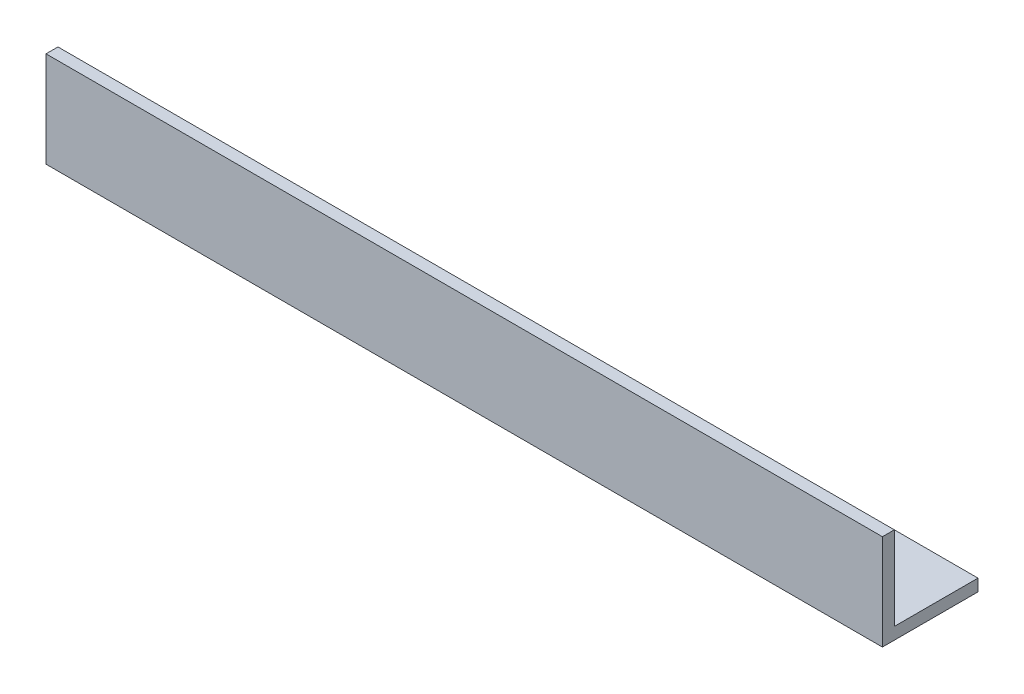
from build123d import *

# Parameters (mm, degrees)
BOSS_EXTRUDE1_DEPTH = 111.125


with BuildPart() as part:
    # Sketch1 → Boss-Extrude1 (new body, symmetric)
    with BuildSketch(Plane(origin=(0, 0, 0), x_dir=(0, 0, -1), z_dir=(1, 0, 0))):
        Polygon((0, 0), (0, 25.4), (3.175, 25.4), (3.175, 3.175), (25.4, 3.175), (25.4, 0), align=None)
    extrude(amount=BOSS_EXTRUDE1_DEPTH, both=True)


solid = part.part
